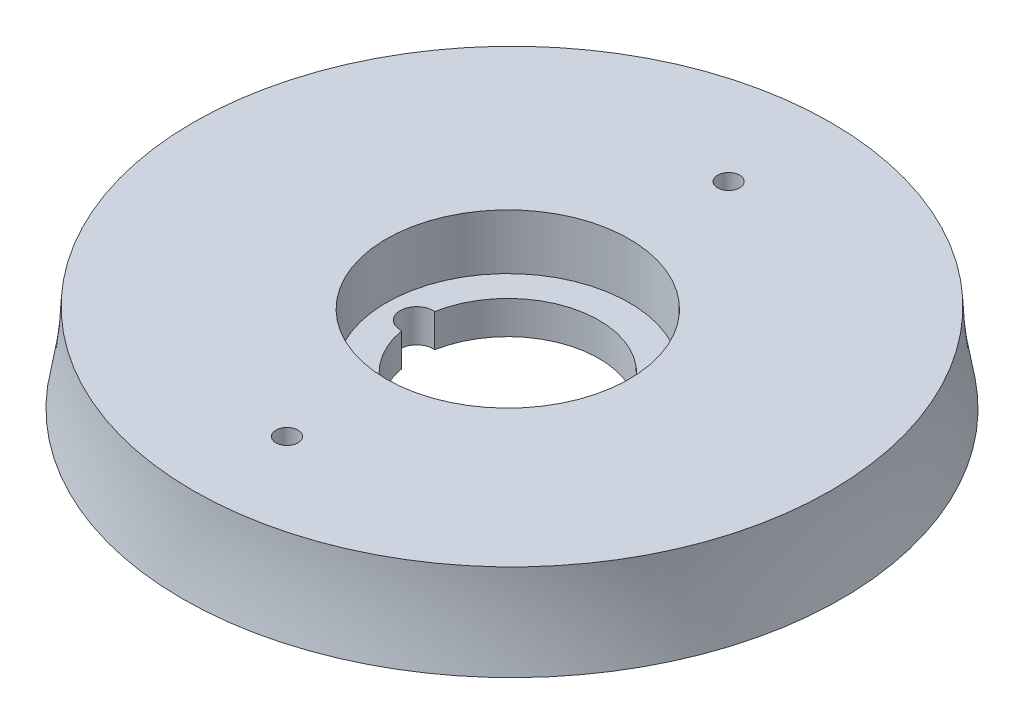
from build123d import *

# Parameters (mm, degrees)
SCHNITT_LINEAR_AUSTRAGEN3_REACH = 45.23
SKIZZE3_R                       = 1
SCHNITT_LINEAR_AUSTRAGEN4_REACH = 45.23
SKIZZE3_4_R                     = 11
SCHNITT_LINEAR_AUSTRAGEN5_DEPTH = 5
SCHNITT_LINEAR_AUSTRAGEN6_REACH = 45.23
SKIZZE3_5_R                     = 1.5


with BuildPart() as part:
    # Skizze1 → Rotation2 (revolve)
    with BuildSketch(Plane(origin=(0, 0, 0), x_dir=(0, 0, -1), z_dir=(1, 0, 0))):
        with BuildLine():
            Line((0.380209453, 2.098852641), (30.229832566, 2.098852641))
            add(Edge.make_bspline(
                [(29.260449341, 10.098852641), (29.33429968, 7.417548621), (29.681552607, 4.815540148), (30.229832566, 2.098852641)],
                knots=[0.538089657, 0.538089657, 0.538089657, 0.538089657, 1, 1, 1, 1], degree=3))
            Line((29.260449341, 10.098852641), (0.380209453, 10.098852641))
            Line((0.380209453, 10.098852641), (0.380209453, 5.098852641))
            Line((0.380209453, 5.098852641), (0.380209453, 2.098852641))
        make_face()
    revolve(axis=Axis((0, 5.098852641, -0.380209453), (0, 1, 0)))

    # Skizze3 → Schnitt-Linear austragen3 (cut, up to next)
    with BuildSketch(Plane(origin=(0, 10.098852641, 0), x_dir=(1, 0, 0), z_dir=(0, 1, 0)), mode=Mode.PRIVATE) as schnitt_linear_austragen3_sk1:
        with Locations((0, 20)):
            Circle(SKIZZE3_R)
    schnitt_linear_austragen3_tool1 = extrude(schnitt_linear_austragen3_sk1.sketch, amount=-SCHNITT_LINEAR_AUSTRAGEN3_REACH, mode=Mode.PRIVATE) & part.part
    # Skizze3 → Schnitt-Linear austragen3 (cut, up to next)
    with BuildSketch(Plane(origin=(0, 10.098852641, 0), x_dir=(1, 0, 0), z_dir=(0, 1, 0)), mode=Mode.PRIVATE) as schnitt_linear_austragen3_sk2:
        with Locations((0, -20)):
            Circle(SKIZZE3_R)
    schnitt_linear_austragen3_tool2 = extrude(schnitt_linear_austragen3_sk2.sketch, amount=-SCHNITT_LINEAR_AUSTRAGEN3_REACH, mode=Mode.PRIVATE) & part.part
    add(schnitt_linear_austragen3_tool1.solids().sort_by_distance((0, 10.098853, -20))[0], mode=Mode.SUBTRACT)
    add(schnitt_linear_austragen3_tool2.solids().sort_by_distance((0, 10.098853, 20))[0], mode=Mode.SUBTRACT)

    # Skizze3_3 → Schnitt-Linear austragen4 (cut, up to next)
    with BuildSketch(Plane(origin=(0, 10.098852641, 0), x_dir=(1, 0, 0), z_dir=(0, 1, 0)), mode=Mode.PRIVATE) as schnitt_linear_austragen4_sk1:
        with BuildLine():
            ThreePointArc((-8.113636364, -1.493788793), (8.25, 0), (-8.113636364, 1.493788793))
            ThreePointArc((-8.113636364, 1.493788793), (-6.75, 0), (-8.113636364, -1.493788793))
        make_face()
    schnitt_linear_austragen4_tool1 = extrude(schnitt_linear_austragen4_sk1.sketch, amount=-SCHNITT_LINEAR_AUSTRAGEN4_REACH, mode=Mode.PRIVATE) & part.part
    add(schnitt_linear_austragen4_tool1.solids().sort_by_distance((0.122549, 10.098853, 0))[0], mode=Mode.SUBTRACT)

    # Skizze3_4 → Schnitt-Linear austragen5 (cut)
    with BuildSketch(Plane(origin=(0, 10.098852641, 0), x_dir=(1, 0, 0), z_dir=(0, 1, 0))):
        Circle(SKIZZE3_4_R)
        with BuildLine():
            ThreePointArc((-8.113636364, -1.493788793), (-9.75, 0), (-8.113636364, 1.493788793))
            ThreePointArc((-8.113636364, 1.493788793), (8.25, 0), (-8.113636364, -1.493788793))
        make_face(mode=Mode.SUBTRACT)
    extrude(amount=-SCHNITT_LINEAR_AUSTRAGEN5_DEPTH, mode=Mode.SUBTRACT)

    # Skizze3_5 → Schnitt-Linear austragen6 (cut, up to next)
    with BuildSketch(Plane(origin=(0, 10.098852641, 0), x_dir=(1, 0, 0), z_dir=(0, 1, 0)), mode=Mode.PRIVATE) as schnitt_linear_austragen6_sk1:
        with Locations((-8.25, 0)):
            Circle(SKIZZE3_5_R)
    schnitt_linear_austragen6_tool1 = extrude(schnitt_linear_austragen6_sk1.sketch, amount=-SCHNITT_LINEAR_AUSTRAGEN6_REACH, mode=Mode.PRIVATE) & part.part
    add(schnitt_linear_austragen6_tool1.solids().sort_by_distance((-8.25, 10.098853, 0))[0], mode=Mode.SUBTRACT)


solid = part.part
